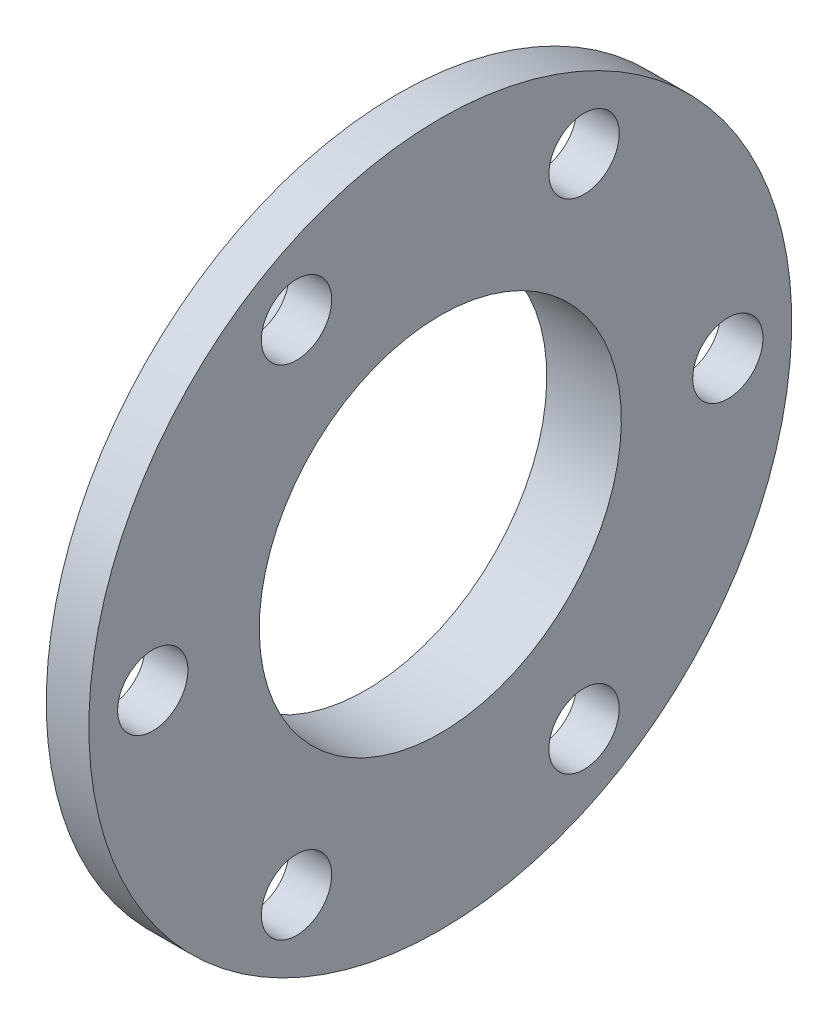
from build123d import *

# Parameters (mm, degrees)
M6_CLEARANCE_HOLE1_D     = 6.6
M6_CLEARANCE_HOLE1_DEPTH = 4
CIRPATTERN1_COUNT        = 6


with BuildPart() as part:
    # Sketch2 → Revolve1 (revolve)
    with BuildSketch(Plane.XY):
        Polygon((-7, 21), (-7, 17), (0, 17), (0, 33), (-4, 33), (-4, 21), align=None)
    revolve(axis=Axis((0, 0, 0), (-1, 0, 0)))

    # M6 Clearance Hole1
    with Locations(Plane(origin=(-4, 0, -27), x_dir=(0, -1, 0), z_dir=(-1, 0, 0))):
        with Locations((0, 0)):
            m6_clearance_hole1 = Hole(M6_CLEARANCE_HOLE1_D / 2, depth=M6_CLEARANCE_HOLE1_DEPTH)

    # CirPattern1: M6 Clearance Hole1 ×6 about axis
    cirpattern1_axis = Axis((0, 0, 0), (1, 0, 0))
    for i in range(1, CIRPATTERN1_COUNT):
        add(m6_clearance_hole1.rotate(cirpattern1_axis, i * 360 / CIRPATTERN1_COUNT), mode=Mode.SUBTRACT)


solid = part.part
